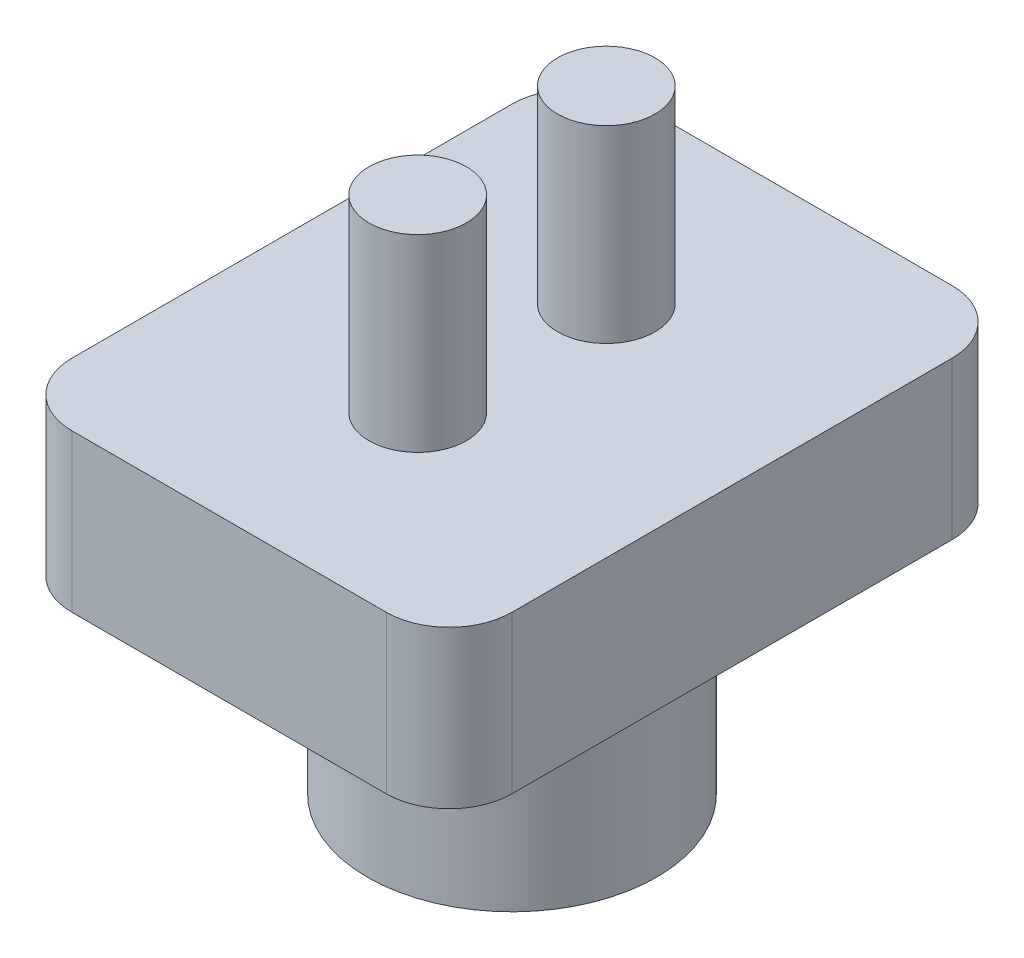
from build123d import *

# Parameters (mm, degrees)
SKETCH1_R           = 4.6
SKETCH1_R_2         = 2.8
ACOPLE_PALITO_DEPTH = 7
CUERPO_START        = 7
SKETCH1_3_W         = 14
SKETCH1_3_H         = 18
CUERPO_DEPTH        = 5
SKETCH2_R           = 1.55
ACOPLE_SENSOR_DEPTH = 6
FILLET1_R           = 2


with BuildPart() as part:
    # Sketch1 → Acople palito (new body)
    with BuildSketch(Plane(origin=(0, 0, 0), x_dir=(1, 0, 0), z_dir=(0, 1, 0))):
        Circle(SKETCH1_R)
        Circle(SKETCH1_R_2, mode=Mode.SUBTRACT)
    extrude(amount=ACOPLE_PALITO_DEPTH)

    # Sketch1_3 → Cuerpo (add)
    with BuildSketch(Plane(origin=(0, 0, 0), x_dir=(1, 0, 0), z_dir=(0, 1, 0)).offset(CUERPO_START)):
        Rectangle(SKETCH1_3_W, SKETCH1_3_H)
    extrude(amount=CUERPO_DEPTH)

    # Sketch2 → Acople sensor (add)
    with BuildSketch(Plane(origin=(0, 12, 0), x_dir=(1, 0, 0), z_dir=(0, 1, 0))):
        with Locations((0, 3)):
            Circle(SKETCH2_R)
        with Locations((0, -3)):
            Circle(SKETCH2_R)
    extrude(amount=ACOPLE_SENSOR_DEPTH)

    # Fillet1
    fillet1_edges = [part.edges().sort_by_distance(p)[0] for p in [
        (7, 9.5, 9),
        (-7, 9.5, 9),
        (-7, 9.5, -9),
        (7, 9.5, -9),
    ]]
    fillet(fillet1_edges, radius=FILLET1_R)


solid = part.part
